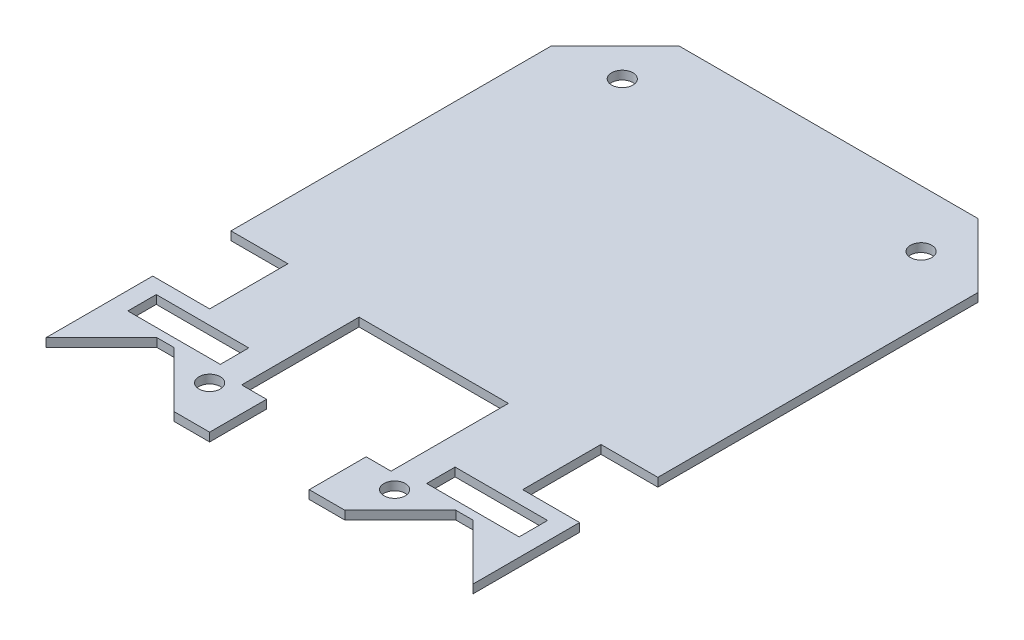
from build123d import *

# Parameters (mm, degrees)
EXTRUDE1_DEPTH               = 1.2
CHAMFER1_SIZE                = 9
F_3_0_3_DIAMETER_HOLE1_D     = 3
F_3_0_3_DIAMETER_HOLE1_DEPTH = 10
F_3_0_3_DIAMETER_HOLE1_TIP   = 0.901290929
CUT_EXTRUDE1_DEPTH           = 10
SKETCH5_W                    = 13
SKETCH5_H                    = 4
CUT_EXTRUDE2_DEPTH           = 10
CUT_EXTRUDE3_DEPTH           = 10


with BuildPart() as part:
    # Sketch1 → Extrude1 (new body)
    with BuildSketch(Plane(origin=(0, 0, 0), x_dir=(1, 0, 0), z_dir=(0, 1, 0))):
        Polygon((-30, -25), (-30, -40), (30, -40), (30, -25), (22, -25), (22, -14), (30, -14), (30, 40), (-30, 40), (-30, -14), (-22, -14), (-22, -25), align=None)
    extrude(amount=EXTRUDE1_DEPTH)

    # Chamfer1
    chamfer1_edges = [part.edges().sort_by_distance(p)[0] for p in [
        (-30, 0.6, -40),
        (30, 0.6, -40),
    ]]
    chamfer(chamfer1_edges, length=CHAMFER1_SIZE)

    # Ø3.0 (3) Diameter Hole1
    with Locations(Plane(origin=(-13, 1.2, 34), x_dir=(0, 0, 1), z_dir=(0, 1, 0))):
        with Locations((0, 0), (0, 26), (-66, 34), (-66, -8)):
            Hole(F_3_0_3_DIAMETER_HOLE1_D / 2, depth=F_3_0_3_DIAMETER_HOLE1_DEPTH)
            with Locations((0, 0, -(F_3_0_3_DIAMETER_HOLE1_DEPTH + F_3_0_3_DIAMETER_HOLE1_TIP / 2))):  # 118° drill point
                Cone(0, F_3_0_3_DIAMETER_HOLE1_D / 2, F_3_0_3_DIAMETER_HOLE1_TIP, mode=Mode.SUBTRACT)

    # Sketch4 → Cut-Extrude1 (cut)
    with BuildSketch(Plane(origin=(0, 1.2, 0), x_dir=(1, 0, 0), z_dir=(0, 1, 0))):
        Polygon((-10.5, -32), (-7, -32), (-7, -40), (7, -40), (7, -32), (10.5, -32), (10.5, -15.5), (-10.5, -15.5), align=None)
    extrude(amount=-CUT_EXTRUDE1_DEPTH, mode=Mode.SUBTRACT)

    # Sketch5 → Cut-Extrude2 (cut)
    with BuildSketch(Plane(origin=(0, 1.2, 0), x_dir=(1, 0, 0), z_dir=(0, 1, 0))):
        with Locations((21, -29)):
            Rectangle(SKETCH5_W, SKETCH5_H)
        with Locations((-21, -29)):
            Rectangle(SKETCH5_W, SKETCH5_H)
    extrude(amount=-CUT_EXTRUDE2_DEPTH, mode=Mode.SUBTRACT)

    # Sketch6 → Cut-Extrude3 (cut)
    with BuildSketch(Plane(origin=(0, 1.2, 0), x_dir=(1, 0, 0), z_dir=(0, 1, 0))):
        Polygon((12, -40), (19.8, -32.2), (22.2, -32.2), (30, -40), align=None)
        Polygon((-30, -40), (-12, -40), (-19.8, -32.2), (-22.2, -32.2), align=None)
    extrude(amount=-CUT_EXTRUDE3_DEPTH, mode=Mode.SUBTRACT)


solid = part.part
